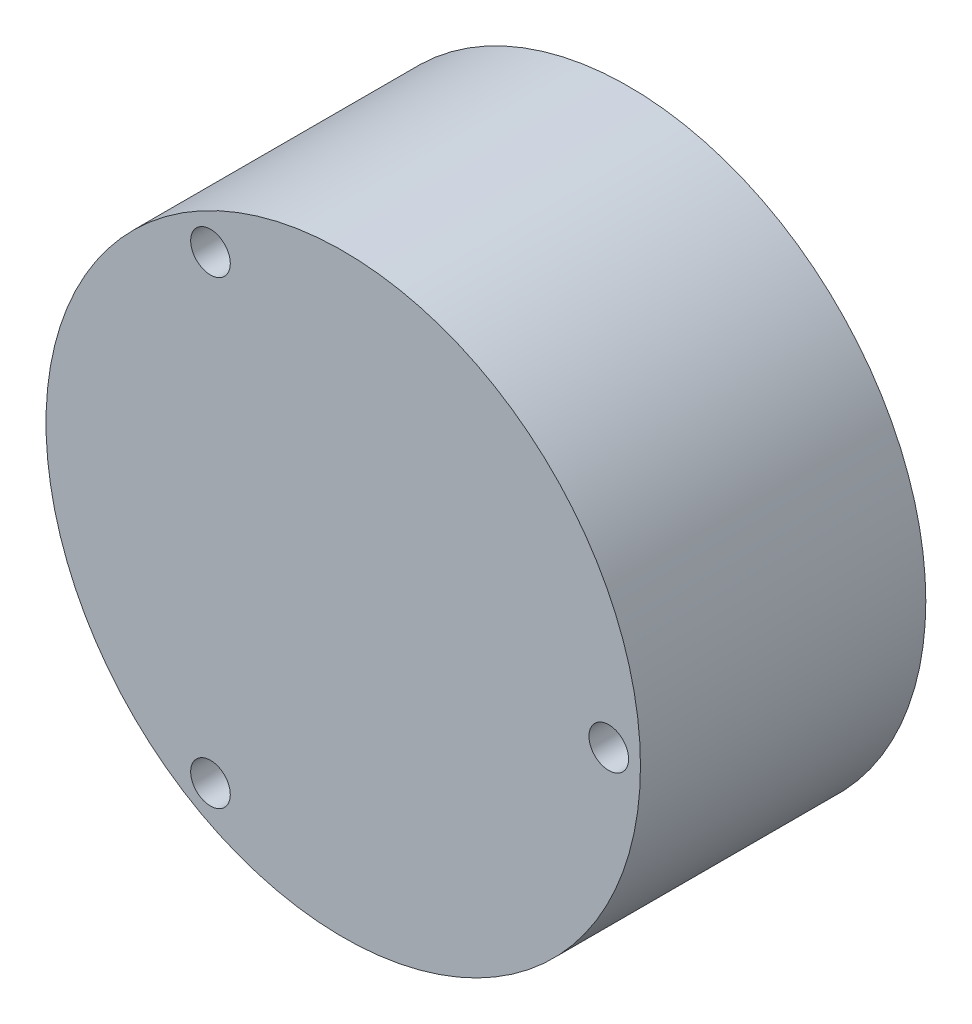
from build123d import *

# Parameters (mm, degrees)
SKETCH_1_R          = 18.75
SKETCH_1_R_2        = 14.5
EXTRUDE_1_DEPTH     = 16
SKETCH_2_R          = 1.25
CUT_EXTRUDE_1_DEPTH = 18
CUT_EXTRUDE_2_DEPTH = 18
SKETCH_4_R          = 18.75
EXTRUDE_2_DEPTH     = 2
SKETCH_6_R          = 1.25
EXTRUDE_3_DEPTH     = 16
SKETCH_7_R          = 1.25
CUT_EXTRUDE_3_DEPTH = 20


with BuildPart() as part:
    # 草图1 → 凸台-拉伸1 (new body)
    with BuildSketch(Plane.XY):
        Circle(SKETCH_1_R)
        Circle(SKETCH_1_R_2, mode=Mode.SUBTRACT)
    extrude(amount=EXTRUDE_1_DEPTH)

    # 草图2 → 切除-拉伸1 (cut)
    with BuildSketch(Plane.XY.offset(16)):
        with Locations((16.625, 0)):
            Circle(SKETCH_2_R)
        with Locations((-8.3125, -14.397672338)):
            Circle(SKETCH_2_R)
        with Locations((-8.3125, 14.397672338)):
            Circle(SKETCH_2_R)
    extrude(amount=-CUT_EXTRUDE_1_DEPTH, mode=Mode.SUBTRACT)

    # 草图3 → 切除-拉伸2 (cut)
    with BuildSketch(Plane.XY.offset(16)):
        with BuildLine():
            ThreePointArc((-7.142590701, -15.756693755), (8.65, -14.982239485), (17.216992422, -1.692681881))
            ThreePointArc((17.216992422, -1.692681881), (14.831783064, 0), (17.216992422, 1.692681881))
            ThreePointArc((17.216992422, 1.692681881), (8.65, 14.982239485), (-7.142590701, 15.756693755))
            ThreePointArc((-7.142590701, 15.756693755), (-7.415891532, 12.844700917), (-10.07440172, 14.064011873))
            ThreePointArc((-10.07440172, 14.064011873), (-17.3, 0), (-10.07440172, -14.064011873))
            ThreePointArc((-10.07440172, -14.064011873), (-7.415891532, -12.844700917), (-7.142590701, -15.756693755))
        make_face()
    extrude(amount=-CUT_EXTRUDE_2_DEPTH, mode=Mode.SUBTRACT)

    # 草图4 → 凸台-拉伸2 (add)
    with BuildSketch(Plane.XY.offset(16)):
        Circle(SKETCH_4_R)
    extrude(amount=EXTRUDE_2_DEPTH)

    # 草图6 → 凸台-拉伸3 (add)
    with BuildSketch(Plane(origin=(0, 0, 0), x_dir=(-1, 0, 0), z_dir=(0, 0, -1))):
        with Locations((8.3125, -14.397672338)):
            Circle(SKETCH_6_R)
        with Locations((-16.625, 0)):
            Circle(SKETCH_6_R)
        with Locations((8.3125, 14.397672338)):
            Circle(SKETCH_6_R)
    extrude(amount=-EXTRUDE_3_DEPTH)

    # 草图7 → 切除-拉伸3 (cut)
    with BuildSketch(Plane(origin=(0, 0, 0), x_dir=(-1, 0, 0), z_dir=(0, 0, -1))):
        with Locations((8.375, 14.505925513)):
            Circle(SKETCH_7_R)
        with Locations((8.375, -14.505925513)):
            Circle(SKETCH_7_R)
        with Locations((-16.75, 0)):
            Circle(SKETCH_7_R)
    extrude(amount=-CUT_EXTRUDE_3_DEPTH, mode=Mode.SUBTRACT)


solid = part.part
